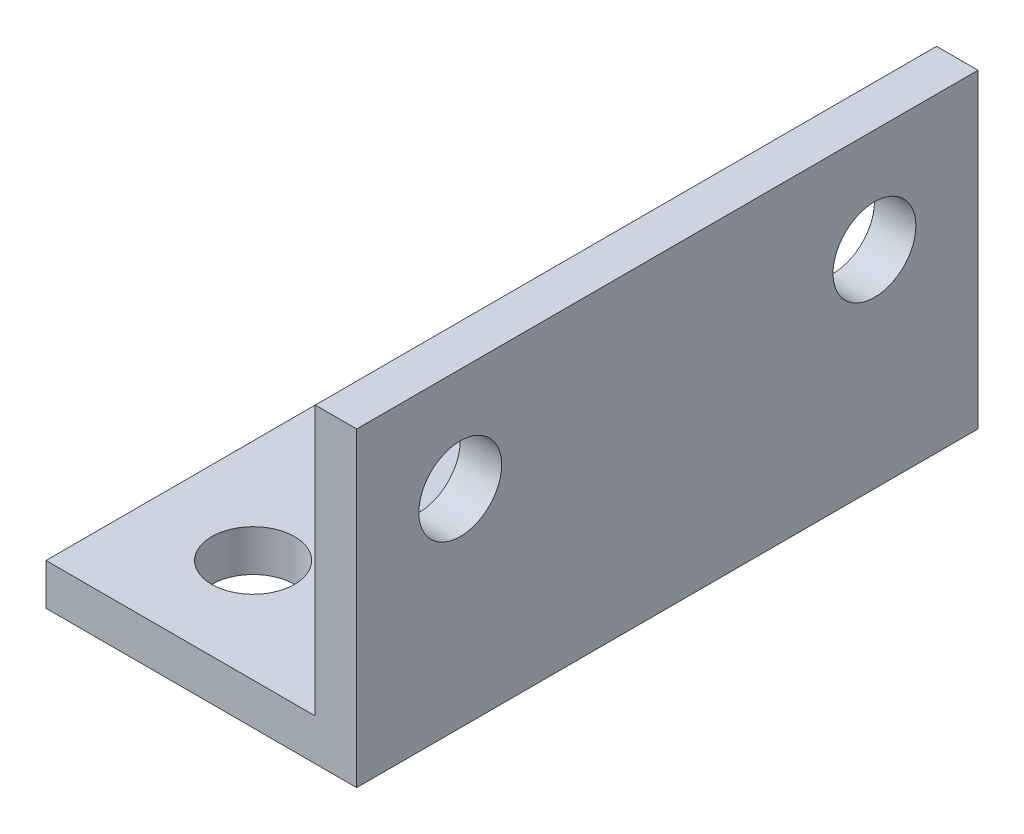
from build123d import *

# Parameters (mm, degrees)
BOSS_EXTRUDE1_DEPTH = 30
CUT_EXTRUDE1_REACH  = 17
SKETCH2_R           = 2
CUT_EXTRUDE2_REACH  = 4
SKETCH3_R           = 2


with BuildPart() as part:
    # Sketch1 → Boss-Extrude1 (new body)
    with BuildSketch(Plane.XY):
        Polygon((0, 15), (0, 0), (-15, 0), (-15, 2), (-2, 2), (-2, 15), align=None)
    extrude(amount=BOSS_EXTRUDE1_DEPTH)

    # Sketch2 → Cut-Extrude1 (cut, up to next)
    with BuildSketch(Plane(origin=(0, 0, 0), x_dir=(0, 0, -1), z_dir=(1, 0, 0)), mode=Mode.PRIVATE) as cut_extrude1_sk1:
        with Locations((-25, 10)):
            Circle(SKETCH2_R)
    cut_extrude1_tool1 = extrude(cut_extrude1_sk1.sketch, amount=-CUT_EXTRUDE1_REACH, mode=Mode.PRIVATE) & part.part
    add(cut_extrude1_tool1.solids().sort_by_distance((0, 10, 25))[0], mode=Mode.SUBTRACT)
    # Sketch2 → Cut-Extrude1 (cut, up to next)
    with BuildSketch(Plane(origin=(0, 0, 0), x_dir=(0, 0, -1), z_dir=(1, 0, 0)), mode=Mode.PRIVATE) as cut_extrude1_sk2:
        with Locations((-5, 10)):
            Circle(SKETCH2_R)
    cut_extrude1_tool2 = extrude(cut_extrude1_sk2.sketch, amount=-CUT_EXTRUDE1_REACH, mode=Mode.PRIVATE) & part.part
    add(cut_extrude1_tool2.solids().sort_by_distance((0, 10, 5))[0], mode=Mode.SUBTRACT)

    # Sketch3 → Cut-Extrude2 (cut, up to next)
    with BuildSketch(Plane(origin=(0, 2, 0), x_dir=(1, 0, 0), z_dir=(0, 1, 0)), mode=Mode.PRIVATE) as cut_extrude2_sk1:
        with Locations((-10, -5)):
            Circle(SKETCH3_R)
    cut_extrude2_tool1 = extrude(cut_extrude2_sk1.sketch, amount=-CUT_EXTRUDE2_REACH, mode=Mode.PRIVATE) & part.part
    add(cut_extrude2_tool1.solids().sort_by_distance((-10, 2, 5))[0], mode=Mode.SUBTRACT)
    # Sketch3 → Cut-Extrude2 (cut, up to next)
    with BuildSketch(Plane(origin=(0, 2, 0), x_dir=(1, 0, 0), z_dir=(0, 1, 0)), mode=Mode.PRIVATE) as cut_extrude2_sk2:
        with Locations((-10, -25)):
            Circle(SKETCH3_R)
    cut_extrude2_tool2 = extrude(cut_extrude2_sk2.sketch, amount=-CUT_EXTRUDE2_REACH, mode=Mode.PRIVATE) & part.part
    add(cut_extrude2_tool2.solids().sort_by_distance((-10, 2, 25))[0], mode=Mode.SUBTRACT)


solid = part.part
